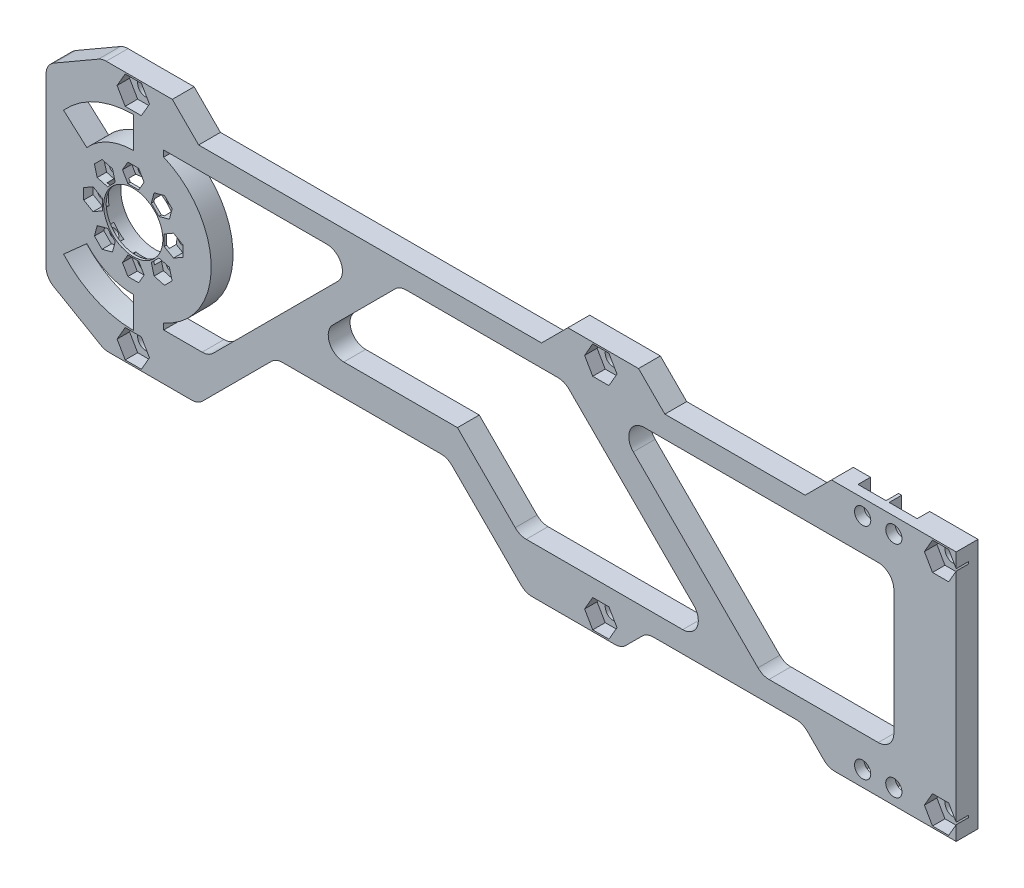
from build123d import *

# Parameters (mm, degrees)
BOSS_EXTRUDE1_DEPTH = 7
SKETCH2_R           = 9.5
CUT_EXTRUDE1_DEPTH  = 7
SKETCH3_R           = 2.6
CUT_EXTRUDE2_DEPTH  = 7
CUT_EXTRUDE4_DEPTH  = 4
SKETCH6_R           = 1.5
CUT_EXTRUDE5_DEPTH  = 8
SKETCH8_R           = 11
CUT_EXTRUDE8_DEPTH  = 6.2
CUT_EXTRUDE10_DEPTH = 4
CUT_EXTRUDE11_DEPTH = 3
CUT_EXTRUDE13_DEPTH = 8
FILLET1_R           = 5
CUT_EXTRUDE15_DEPTH = 8
CUT_EXTRUDE16_DEPTH = 8
CUT_EXTRUDE17_DEPTH = 8
FILLET4_R           = 5
FILLET5_R           = 5


with BuildPart() as part:
    # Sketch1 → Boss-Extrude1 (new body)
    with BuildSketch(Plane.XY):
        Polygon((0, 0), (-274, 0), (-299.980762114, -15), (-299.980762114, -65), (-273.220681495, -80.449939749), (-243.220681495, -80.449939749), (-218.189101441, -55.418359695), (-163.189101441, -55.418359695), (-138.157521387, -80.449939749), (0, -80.449939749), align=None)
    extrude(amount=BOSS_EXTRUDE1_DEPTH)

    # Sketch2 → Cut-Extrude1 (cut)
    with BuildSketch(Plane.XY.offset(7)):
        with Locations((-263.980762114, -40.449939749)):
            Circle(SKETCH2_R)
    extrude(amount=-CUT_EXTRUDE1_DEPTH, mode=Mode.SUBTRACT)

    # Sketch3 → Cut-Extrude2 (cut)
    with BuildSketch(Plane.XY.offset(7)):
        with Locations((-263.980762114, -75.449939749)):
            Circle(SKETCH3_R)
        with Locations((-114, -75.449939749)):
            Circle(SKETCH3_R)
        with Locations((-30, -75.449939749)):
            Circle(SKETCH3_R)
        with Locations((-20, -75.449939749)):
            Circle(SKETCH3_R)
        with Locations((-5, -75.449939749)):
            Circle(SKETCH3_R)
        with Locations((-5, -5)):
            Circle(SKETCH3_R)
        with Locations((-20, -5)):
            Circle(SKETCH3_R)
        with Locations((-30, -5)):
            Circle(SKETCH3_R)
        with Locations((-114, -5)):
            Circle(SKETCH3_R)
        with Locations((-263.980762114, -5)):
            Circle(SKETCH3_R)
    extrude(amount=-CUT_EXTRUDE2_DEPTH, mode=Mode.SUBTRACT)

    # Sketch5 → Cut-Extrude4 (cut)
    with BuildSketch(Plane(origin=(0, 0, 0), x_dir=(-1, 0, 0), z_dir=(0, 0, -1))):
        with BuildLine():
            Line((15.5, -5), (15.5, 0))
            Line((15.5, 0), (24.5, 0))
            Line((24.5, 0), (24.5, -5))
            ThreePointArc((24.5, -5), (20, -9.5), (15.5, -5))
        make_face()
        with BuildLine():
            Line((25.5, -5), (25.5, 0))
            Line((25.5, 0), (34.5, 0))
            Line((34.5, 0), (34.5, -5))
            ThreePointArc((34.5, -5), (30, -9.5), (25.5, -5))
        make_face()
        with BuildLine():
            Line((34.5, -75.449939749), (34.5, -80.449939749))
            Line((34.5, -80.449939749), (25.5, -80.449939749))
            Line((25.5, -80.449939749), (25.5, -75.449939749))
            ThreePointArc((25.5, -75.449939749), (30, -70.949939749), (34.5, -75.449939749))
        make_face()
        with BuildLine():
            Line((24.5, -75.449939749), (24.5, -80.449939749))
            Line((24.5, -80.449939749), (15.5, -80.449939749))
            Line((15.5, -80.449939749), (15.5, -75.449939749))
            ThreePointArc((15.5, -75.449939749), (20, -70.949939749), (24.5, -75.449939749))
        make_face()
    extrude(amount=-CUT_EXTRUDE4_DEPTH, mode=Mode.SUBTRACT)

    # Sketch6 → Cut-Extrude5 (cut, through all)
    with BuildSketch(Plane(origin=(0, 0, 0), x_dir=(-1, 0, 0), z_dir=(0, 0, -1))):
        with Locations((263.980762114, -27.549939749)):
            Circle(SKETCH6_R)
        with Locations((273.102439591, -31.328262272)):
            Circle(SKETCH6_R)
        with Locations((276.880762114, -40.449939749)):
            Circle(SKETCH6_R)
        with Locations((273.102439591, -49.571617226)):
            Circle(SKETCH6_R)
        with Locations((263.980762114, -53.349939749)):
            Circle(SKETCH6_R)
        with Locations((254.859084636, -49.571617226)):
            Circle(SKETCH6_R)
        with Locations((251.080762114, -40.449939749)):
            Circle(SKETCH6_R)
        with Locations((254.859084636, -31.328262272)):
            Circle(SKETCH6_R)
    extrude(amount=-CUT_EXTRUDE5_DEPTH, mode=Mode.SUBTRACT)

    # Sketch8 → Cut-Extrude8 (cut)
    with BuildSketch(Plane(origin=(0, 0, 0), x_dir=(-1, 0, 0), z_dir=(0, 0, -1))):
        with Locations((263.980762114, -40.449939749)):
            Circle(SKETCH8_R)
    extrude(amount=-CUT_EXTRUDE8_DEPTH, mode=Mode.SUBTRACT)

    # Sketch10 → Cut-Extrude10 (cut)
    with BuildSketch(Plane.XY.offset(7)):
        Polygon((-258.784609691, -5), (-261.382685902, -0.5), (-266.578838325, -0.5), (-269.176914536, -5), (-266.578838325, -9.5), (-261.382685902, -9.5), align=None)
        Polygon((-108.803847577, -5), (-111.401923789, -0.5), (-116.598076211, -0.5), (-119.196152423, -5), (-116.598076211, -9.5), (-111.401923789, -9.5), align=None)
        Polygon((0.196152423, -5), (-2.401923789, -0.5), (-7.598076211, -0.5), (-10.196152423, -5), (-7.598076211, -9.5), (-2.401923789, -9.5), align=None)
        Polygon((-2.401923789, -70.949939749), (0.196152423, -75.449939749), (-2.401923789, -79.949939749), (-7.598076211, -79.949939749), (-10.196152423, -75.449939749), (-7.598076211, -70.949939749), align=None)
        Polygon((-111.401923789, -70.949939749), (-108.803847577, -75.449939749), (-111.401923789, -79.949939749), (-116.598076211, -79.949939749), (-119.196152423, -75.449939749), (-116.598076211, -70.949939749), align=None)
        Polygon((-261.382685902, -70.949939749), (-258.784609691, -75.449939749), (-261.382685902, -79.949939749), (-266.578838325, -79.949939749), (-269.176914536, -75.449939749), (-266.578838325, -70.949939749), align=None)
    extrude(amount=-CUT_EXTRUDE10_DEPTH, mode=Mode.SUBTRACT)

    # Sketch11 → Cut-Extrude11 (cut)
    with BuildSketch(Plane.XY.offset(7)):
        Polygon((-252.409594893, -33.777752014), (-251.513019421, -30.431686799), (-253.962509164, -27.982197057), (-257.308574379, -28.878772529), (-258.205149851, -32.224837744), (-255.755660108, -34.674327486), align=None)
        Polygon((-260.516660498, -27.549939749), (-262.248711306, -24.549939749), (-265.712812921, -24.549939749), (-267.444863729, -27.549939749), (-265.712812921, -30.549939749), (-262.248711306, -30.549939749), align=None)
        Polygon((-251.080762114, -43.914041364), (-248.080762114, -42.181990556), (-248.080762114, -38.717888941), (-251.080762114, -36.985838134), (-254.080762114, -38.717888941), (-254.080762114, -42.181990556), align=None)
        Polygon((-257.308574379, -52.021106969), (-253.962509164, -52.917682441), (-251.513019421, -50.468192698), (-252.409594893, -47.122127483), (-255.755660108, -46.225552011), (-258.205149851, -48.675041754), align=None)
        Polygon((-267.444863729, -53.349939749), (-265.712812921, -56.349939749), (-262.248711306, -56.349939749), (-260.516660498, -53.349939749), (-262.248711306, -50.349939749), (-265.712812921, -50.349939749), align=None)
        Polygon((-275.551929334, -47.122127483), (-276.448504806, -50.468192698), (-273.999015063, -52.917682441), (-270.652949848, -52.021106969), (-269.756374376, -48.675041754), (-272.205864119, -46.225552011), align=None)
        Polygon((-276.880762114, -36.985838134), (-279.880762114, -38.717888941), (-279.880762114, -42.181990556), (-276.880762114, -43.914041364), (-273.880762114, -42.181990556), (-273.880762114, -38.717888941), align=None)
        Polygon((-270.652949848, -28.878772529), (-273.999015063, -27.982197057), (-276.448504806, -30.431686799), (-275.551929334, -33.777752014), (-272.205864119, -34.674327486), (-269.756374376, -32.224837744), align=None)
    extrude(amount=-CUT_EXTRUDE11_DEPTH, mode=Mode.SUBTRACT)

    # Sketch12 → Cut-Extrude13 (cut, through all)
    with BuildSketch(Plane(origin=(0, 0, 0), x_dir=(-1, 0, 0), z_dir=(0, 0, -1))):
        Polygon((20, -15.449939749), (112.110331411, -15.449939749), (62.110331411, -65.449939749), (20, -65.449939749), align=None)
        Polygon((140, -65.449939749), (159.990168204, -45.459771544), (208.515896653, -45.459771544), (178.506064857, -15.449939749), (140, -15.449939749), (125.651667005, -15.449939749), (75.651667005, -65.449939749), align=None)
        with BuildLine():
            Line((219.829605152, -45.459771544), (239.819773356, -65.449939749))
            Line((239.819773356, -65.449939749), (254.21442913, -65.449939749))
            Line((254.21442913, -65.449939749), (254.21442913, -63.463386689))
            ThreePointArc((254.21442913, -63.463386689), (238.980762114, -40.449939749), (254.21442913, -17.436492809))
            Line((254.21442913, -17.436492809), (254.21442913, -15.449939749))
            Line((254.21442913, -15.449939749), (189.819773356, -15.449939749))
            Line((189.819773356, -15.449939749), (219.829605152, -45.459771544))
        make_face()
    extrude(amount=-CUT_EXTRUDE13_DEPTH, mode=Mode.SUBTRACT)

    # Fillet1
    fillet1_edges = [part.edges().sort_by_distance(p)[0] for p in [
        (-189.819773356, -15.449939749, 3.5),
        (-239.819773356, -65.449939749, 3.5),
        (-20, -65.449939749, 3.5),
        (-20, -15.449939749, 3.5),
        (-112.110331411, -15.449939749, 3.5),
        (-62.110331411, -65.449939749, 3.5),
        (-140, -65.449939749, 3.5),
        (-75.651667005, -65.449939749, 3.5),
        (-125.651667005, -15.449939749, 3.5),
        (-178.506064857, -15.449939749, 3.5),
        (-208.515896653, -45.459771544, 3.5),
    ]]
    fillet(fillet1_edges, radius=FILLET1_R)

    # Sketch13 → Cut-Extrude15 (cut, through all)
    with BuildSketch(Plane(origin=(0, 0, 0), x_dir=(-1, 0, 0), z_dir=(0, 0, -1))):
        Polygon((40, 0), (48.449939749, -8.449939749), (93.449939749, -8.449939749), (101.899879498, 0), align=None)
        Polygon((124.566765904, 0), (133.016705653, -8.449939749), (243.016705653, -8.449939749), (251.466645402, 0), align=None)
        with BuildLine():
            Line((263.980762114, -60.449939749), (263.980762114, -70.449939749))
            ThreePointArc((263.980762114, -70.449939749), (276.228210827, -67.836067624), (286.341441889, -60.449939749))
            Line((286.341441889, -60.449939749), (278.887881964, -53.783273082))
            ThreePointArc((278.887881964, -53.783273082), (272.145727923, -58.707358332), (263.980762114, -60.449939749))
        make_face()
        with BuildLine():
            Line((263.980762114, -20.449939749), (263.980762114, -10.449939749))
            ThreePointArc((263.980762114, -10.449939749), (276.228210827, -13.063811874), (286.341441889, -20.449939749))
            Line((286.341441889, -20.449939749), (278.887881964, -27.116606415))
            ThreePointArc((278.887881964, -27.116606415), (272.145727923, -22.192521165), (263.980762114, -20.449939749))
        make_face()
    extrude(amount=-CUT_EXTRUDE15_DEPTH, mode=Mode.SUBTRACT)

    # Sketch14 → Cut-Extrude16 (cut, through all)
    with BuildSketch(Plane(origin=(0, 0, 0), x_dir=(-1, 0, 0), z_dir=(0, 0, -1))):
        Polygon((291.980762114, -69.618802154), (291.980762114, -10.381197846), (299.980762114, -15), (299.980762114, -65), align=None)
    extrude(amount=-CUT_EXTRUDE16_DEPTH, mode=Mode.SUBTRACT)

    # Sketch15 → Cut-Extrude17 (cut, through all)
    with BuildSketch(Plane(origin=(0, 0, 0), x_dir=(-1, 0, 0), z_dir=(0, 0, -1))):
        Polygon((41.003675817, -80.449939749), (49.221382908, -72.232232658), (99.221382908, -72.232232658), (107.439089999, -80.449939749), align=None)
    extrude(amount=-CUT_EXTRUDE17_DEPTH, mode=Mode.SUBTRACT)

    # Fillet4
    fillet4_edges = [part.edges().sort_by_distance(p)[0] for p in [
        (-273.220681495, -80.449939749, 3.5),
        (-274, 0, 3.5),
        (-291.980762114, -69.618802154, 3.5),
        (-291.980762114, -10.381197846, 3.5),
    ]]
    fillet(fillet4_edges, radius=FILLET4_R)

    # Fillet5
    fillet5_edges = [part.edges().sort_by_distance(p)[0] for p in [
        (-138.157521387, -80.449939749, 3.5),
        (-163.189101441, -55.418359695, 3.5),
        (-218.189101441, -55.418359695, 3.5),
        (-243.220681495, -80.449939749, 3.5),
        (-107.439089999, -80.449939749, 3.5),
        (-41.003675817, -80.449939749, 3.5),
        (-49.221382908, -72.232232658, 3.5),
        (-99.221382908, -72.232232658, 3.5),
    ]]
    fillet(fillet5_edges, radius=FILLET5_R)


solid = part.part
